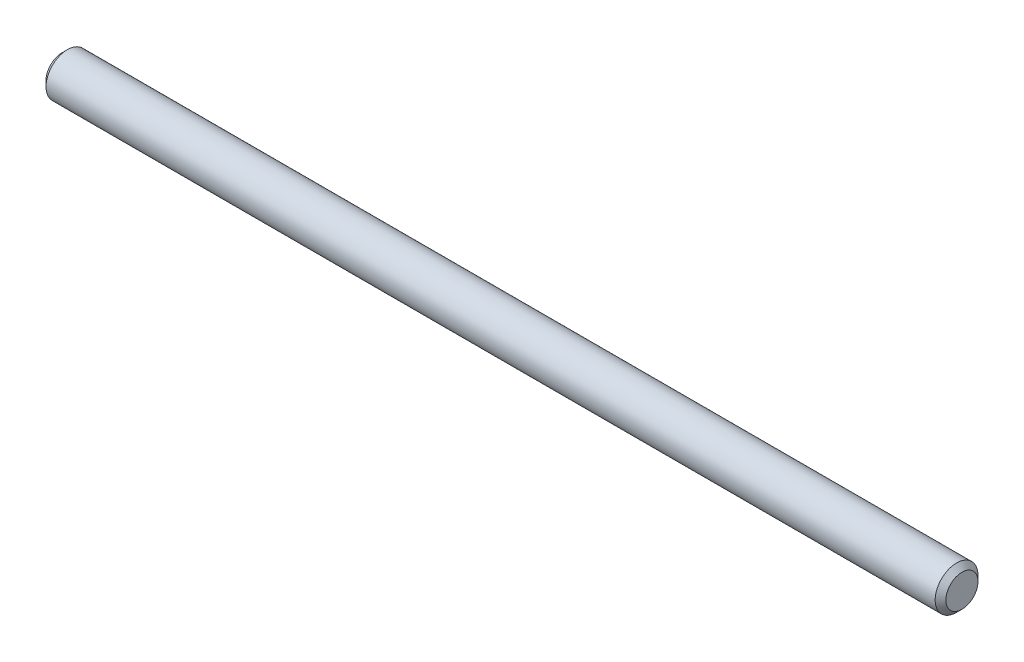
from build123d import *

# Parameters (mm, degrees)
SKETCH1_R           = 2
BOSS_EXTRUDE1_DEPTH = 84
CHAMFER1_SIZE       = 0.5


with BuildPart() as part:
    # Sketch1 → Boss-Extrude1 (new body)
    with BuildSketch(Plane(origin=(0, 0, 0), x_dir=(0, 0, -1), z_dir=(1, 0, 0))):
        Circle(SKETCH1_R)
    extrude(amount=BOSS_EXTRUDE1_DEPTH)

    # Chamfer1
    chamfer1_edges = [part.edges().sort_by_distance(p)[0] for p in [
        (0, 0, 2),
        (84, 0, 2),
    ]]
    chamfer(chamfer1_edges, length=CHAMFER1_SIZE)


solid = part.part
